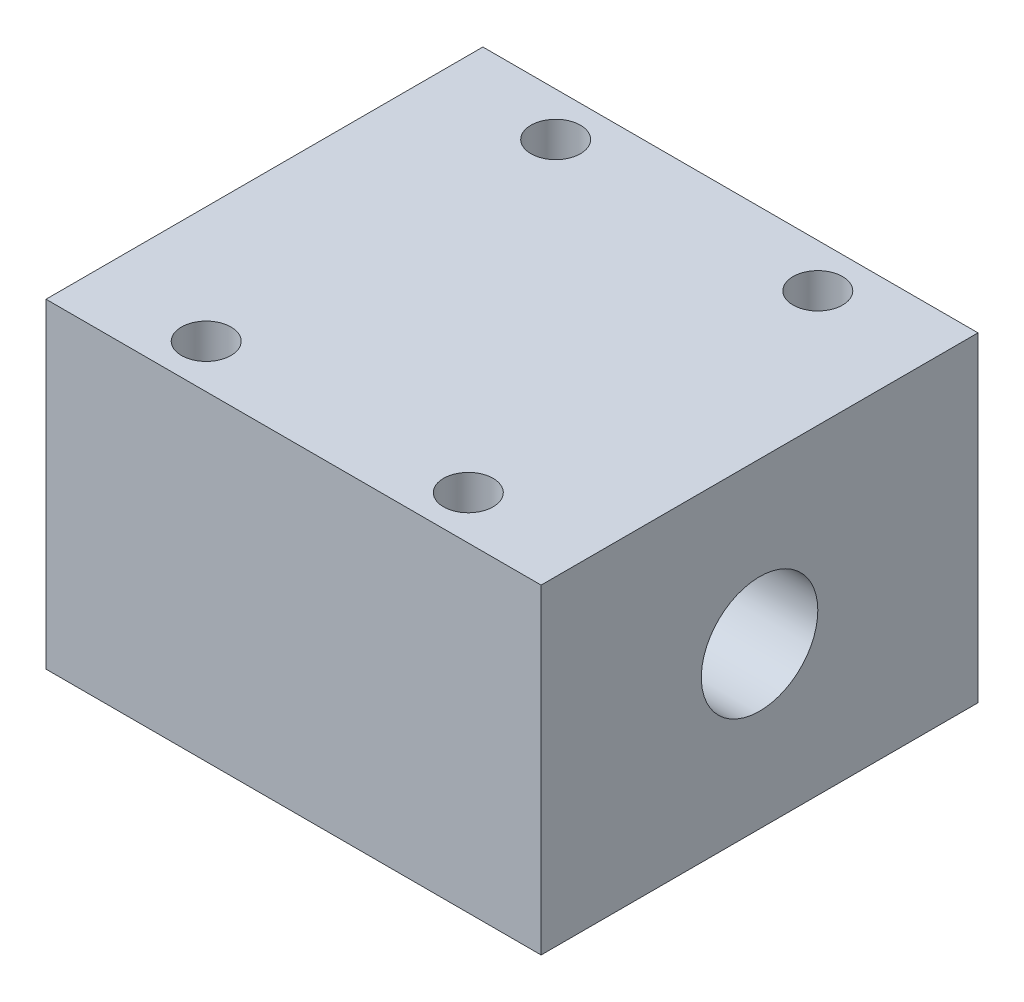
from build123d import *

# Parameters (mm, degrees)
SKETCH1_W           = 34
SKETCH1_H           = 30
SKETCH1_R           = 1.7
BOSS_EXTRUDE1_DEPTH = 22
SKETCH4_R           = 4
CUT_EXTRUDE2_DEPTH  = 42


with BuildPart() as part:
    # Sketch1 → Boss-Extrude1 (new body)
    with BuildSketch(Plane(origin=(0, 0, 0), x_dir=(1, 0, 0), z_dir=(0, 1, 0))):
        Rectangle(SKETCH1_W, SKETCH1_H)
        with Locations((-9, 12)):
            Circle(SKETCH1_R, mode=Mode.SUBTRACT)
        with Locations((9, 12)):
            Circle(SKETCH1_R, mode=Mode.SUBTRACT)
        with Locations((9, -12)):
            Circle(SKETCH1_R, mode=Mode.SUBTRACT)
        with Locations((-9, -12)):
            Circle(SKETCH1_R, mode=Mode.SUBTRACT)
    extrude(amount=BOSS_EXTRUDE1_DEPTH)

    # Sketch4 → Cut-Extrude2 (cut)
    with BuildSketch(Plane(origin=(17, 0, 0), x_dir=(0, 0, -1), z_dir=(1, 0, 0))):
        with Locations((0, 11)):
            Circle(SKETCH4_R)
    extrude(amount=-CUT_EXTRUDE2_DEPTH, mode=Mode.SUBTRACT)


solid = part.part
